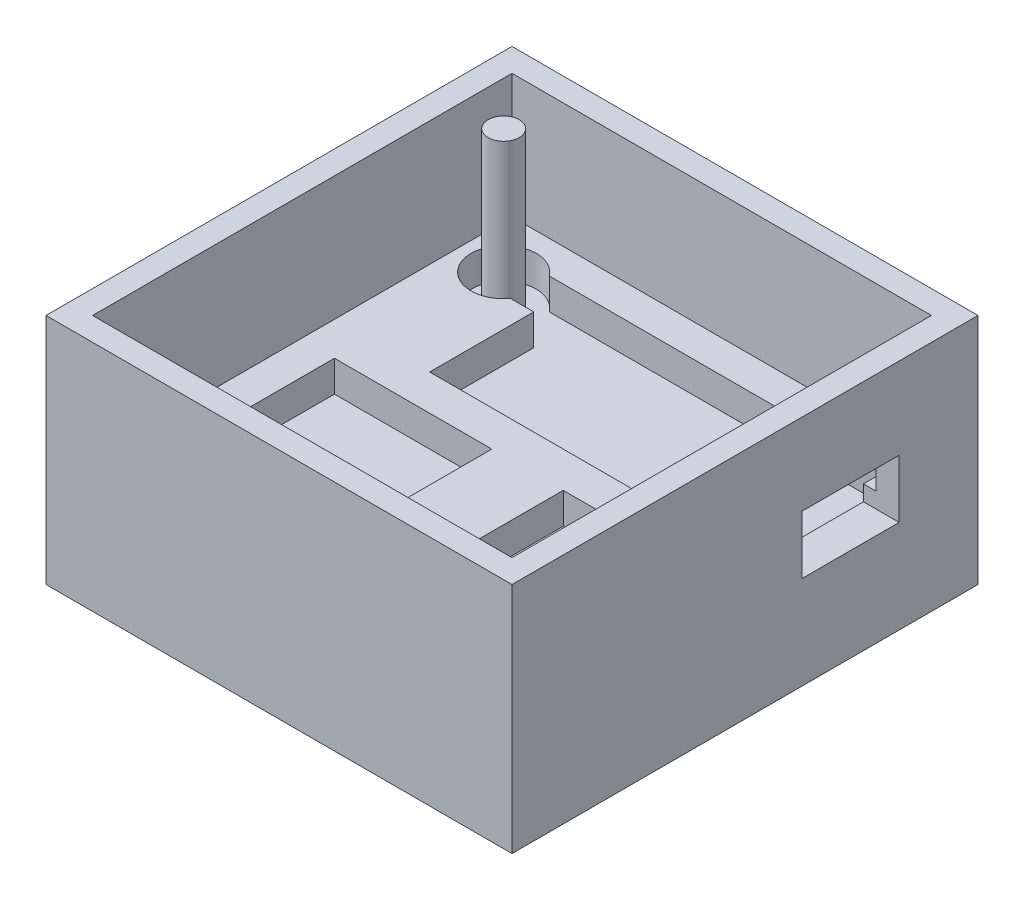
from build123d import *

# Parameters (mm, degrees)
SKETCH1_W           = 76.2
SKETCH1_H           = 76.2
BOSS_EXTRUDE1_DEPTH = 38.1
SKETCH2_W           = 51.308
SKETCH2_H           = 23.368
SKETCH2_W_2         = 23.622
SKETCH2_H_2         = 30.988
SKETCH2_W_3         = 25.7302
SKETCH2_H_3         = 28.5242
CUT_EXTRUDE3_DEPTH  = 25.4
SKETCH8_W           = 68.58
SKETCH8_H           = 68.58
SKETCH8_W_2         = 25.7302
SKETCH8_H_2         = 28.5242
SKETCH8_W_3         = 23.622
SKETCH8_H_3         = 30.988
SKETCH8_W_4         = 51.308
SKETCH8_H_4         = 23.368
CUT_EXTRUDE5_DEPTH  = 20.32
SKETCH10_W          = 15.875
SKETCH10_H          = 9.525
CUT_EXTRUDE6_DEPTH  = 20.32
CUT_EXTRUDE7_DEPTH  = 5.08
SKETCH12_R          = 2.54
BOSS_EXTRUDE2_DEPTH = 25.4


with BuildPart() as part:
    # Sketch1 → Boss-Extrude1 (new body)
    with BuildSketch(Plane(origin=(0, 0, 0), x_dir=(1, 0, 0), z_dir=(0, 1, 0))):
        Rectangle(SKETCH1_W, SKETCH1_H)
    extrude(amount=BOSS_EXTRUDE1_DEPTH)

    # Sketch2 → Cut-Extrude3 (cut)
    with BuildSketch(Plane(origin=(0, 38.1, 0), x_dir=(1, 0, 0), z_dir=(0, 1, 0))):
        with Locations((6.604, 17.272)):
            Rectangle(SKETCH2_W, SKETCH2_H)
        with Locations((20.447, -15.748)):
            Rectangle(SKETCH2_W_2, SKETCH2_H_2)
        with Locations((-15.9131, -14.5161)):
            Rectangle(SKETCH2_W_3, SKETCH2_H_3)
    extrude(amount=-CUT_EXTRUDE3_DEPTH, mode=Mode.SUBTRACT)

    # Sketch8 → Cut-Extrude5 (cut)
    with BuildSketch(Plane(origin=(0, 38.1, 0), x_dir=(1, 0, 0), z_dir=(0, 1, 0))):
        Rectangle(SKETCH8_W, SKETCH8_H)
        with Locations((-15.9131, -14.5161)):
            Rectangle(SKETCH8_W_2, SKETCH8_H_2, mode=Mode.SUBTRACT)
        with Locations((20.447, -15.748)):
            Rectangle(SKETCH8_W_3, SKETCH8_H_3, mode=Mode.SUBTRACT)
        with Locations((6.604, 17.272)):
            Rectangle(SKETCH8_W_4, SKETCH8_H_4, mode=Mode.SUBTRACT)
    extrude(amount=-CUT_EXTRUDE5_DEPTH, mode=Mode.SUBTRACT)

    # Sketch10 → Cut-Extrude6 (cut)
    with BuildSketch(Plane(origin=(38.1, 0, 0), x_dir=(0, 0, -1), z_dir=(1, 0, 0))):
        with Locations((17.272, 20.0025)):
            Rectangle(SKETCH10_W, SKETCH10_H)
    extrude(amount=-CUT_EXTRUDE6_DEPTH, mode=Mode.SUBTRACT)

    # Sketch11 → Cut-Extrude7 (cut)
    with BuildSketch(Plane(origin=(0, 17.78, 0), x_dir=(1, 0, 0), z_dir=(0, 1, 0))):
        with BuildLine():
            Line((-19.05, 28.956), (-19.05, 22.606))
            Line((-19.05, 22.606), (-22.86, 22.606))
            ThreePointArc((-22.86, 22.606), (-32.470396483, 25.781), (-22.86, 28.956))
            Line((-22.86, 28.956), (-19.05, 28.956))
        make_face()
    extrude(amount=-CUT_EXTRUDE7_DEPTH, mode=Mode.SUBTRACT)

    # Sketch12 → Boss-Extrude2 (add)
    with BuildSketch(Plane(origin=(0, 12.7, 0), x_dir=(1, 0, 0), z_dir=(0, 1, 0))):
        with Locations((-27.140733667, 25.781)):
            Circle(SKETCH12_R)
    extrude(amount=BOSS_EXTRUDE2_DEPTH)


solid = part.part
